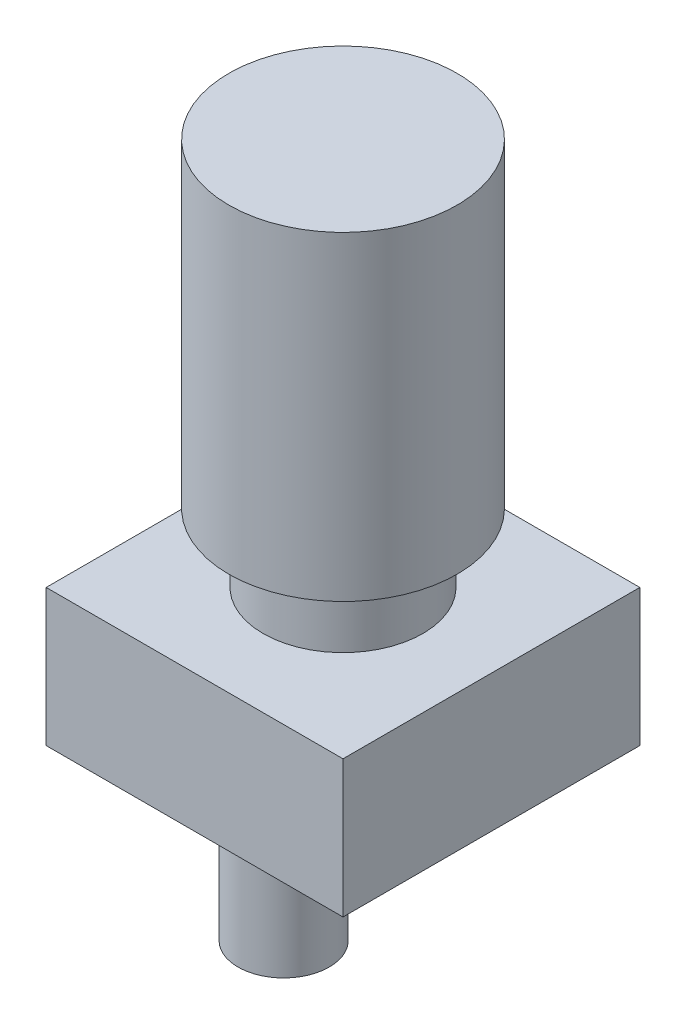
from build123d import *

# Parameters (mm, degrees)
SKETCH1_W           = 65
SKETCH1_H           = 65
BOSS_EXTRUDE1_DEPTH = 30
SKETCH3_R           = 17.5
BOSS_EXTRUDE2_DEPTH = 15
SKETCH4_R           = 25
BOSS_EXTRUDE3_DEPTH = 70
SKETCH5_R           = 7.5
BOSS_EXTRUDE4_DEPTH = 3
SKETCH6_R           = 4
BOSS_EXTRUDE5_DEPTH = 10
SKETCH7_R           = 10
BOSS_EXTRUDE6_DEPTH = 30
CUT_EXTRUDE1_DEPTH  = 22.38


with BuildPart() as part:
    # Sketch1 → Boss-Extrude1 (new body)
    with BuildSketch(Plane(origin=(0, 0, 0), x_dir=(1, 0, 0), z_dir=(0, 1, 0))):
        Rectangle(SKETCH1_W, SKETCH1_H)
    extrude(amount=BOSS_EXTRUDE1_DEPTH)

    # Sketch3 → Boss-Extrude2 (add)
    with BuildSketch(Plane(origin=(0, 30, 0), x_dir=(1, 0, 0), z_dir=(0, 1, 0))):
        Circle(SKETCH3_R)
    extrude(amount=BOSS_EXTRUDE2_DEPTH)

    # Sketch4 → Boss-Extrude3 (add)
    with BuildSketch(Plane(origin=(0, 45, 0), x_dir=(1, 0, 0), z_dir=(0, 1, 0))):
        Circle(SKETCH4_R)
    extrude(amount=BOSS_EXTRUDE3_DEPTH)

    # Sketch5 → Boss-Extrude4 (add)
    with BuildSketch(Plane.XZ):
        with Locations((-12.500000122, 0.50000004)):
            Circle(SKETCH5_R)
    extrude(amount=BOSS_EXTRUDE4_DEPTH)

    # Sketch6 → Boss-Extrude5 (add)
    with BuildSketch(Plane.XZ.offset(3)):
        with Locations((-12.500000122, 0.50000004)):
            Circle(SKETCH6_R)
    extrude(amount=BOSS_EXTRUDE5_DEPTH)

    # Sketch7 → Boss-Extrude6 (add)
    with BuildSketch(Plane.XZ.offset(13)):
        with Locations((-12.500000122, 0.50000004)):
            Circle(SKETCH7_R)
    extrude(amount=BOSS_EXTRUDE6_DEPTH)

    # Sketch8 → Cut-Extrude1 (cut)
    with BuildSketch(Plane.XZ.offset(43)):
        with BuildLine():
            Line((-17.733861002, 3.106945343), (-7.140648736, 3.106945343))
            ThreePointArc((-7.140648736, 3.106945343), (-12.437254869, -3.029833946), (-17.733861002, 3.106945343))
        make_face()
    extrude(amount=-CUT_EXTRUDE1_DEPTH, mode=Mode.SUBTRACT)


solid = part.part
